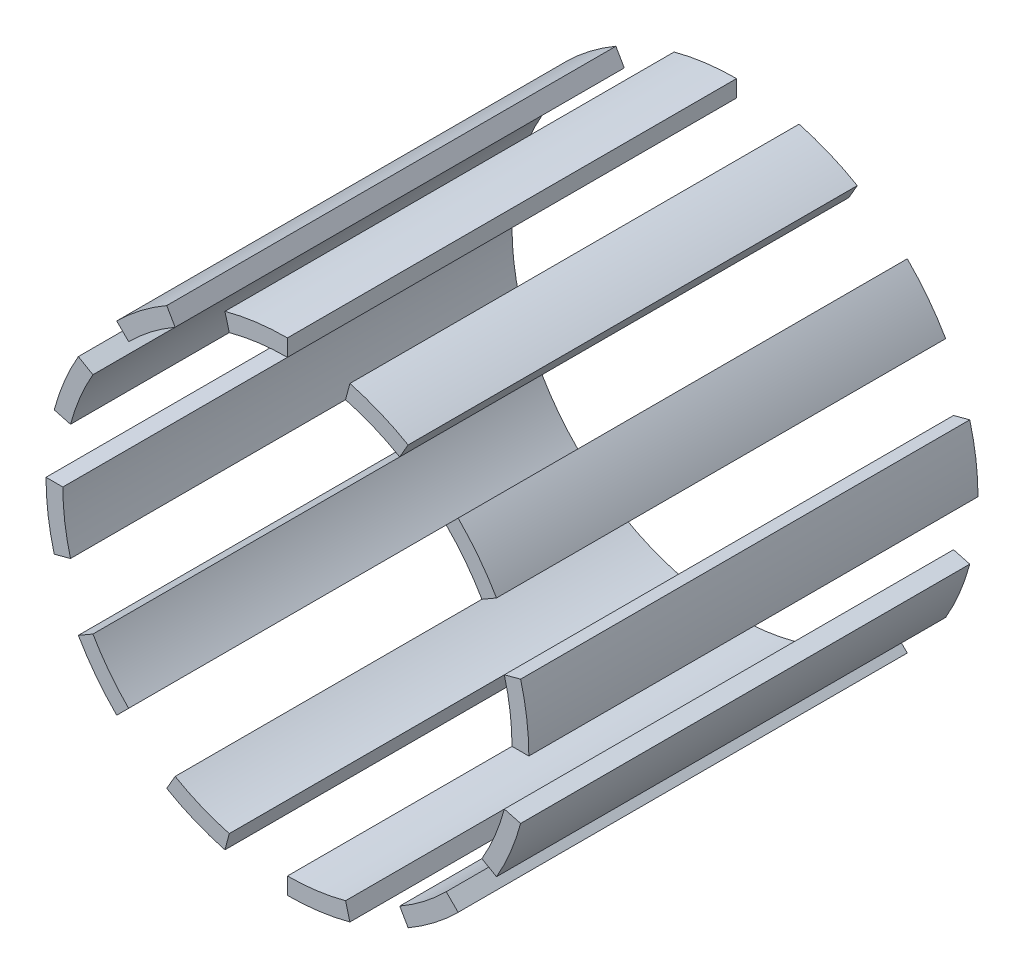
from build123d import *

# Parameters (mm, degrees)
BOSS_EXTRU_1_DEPTH    = 16
BOSS_EXTRU_1_2_DEPTH  = 16
BOSS_EXTRU_1_3_DEPTH  = 16
BOSS_EXTRU_1_4_DEPTH  = 16
BOSS_EXTRU_1_5_DEPTH  = 16
BOSS_EXTRU_1_6_DEPTH  = 16
BOSS_EXTRU_1_7_DEPTH  = 16
BOSS_EXTRU_1_8_DEPTH  = 16
BOSS_EXTRU_1_9_DEPTH  = 16
BOSS_EXTRU_1_10_DEPTH = 16
BOSS_EXTRU_1_11_DEPTH = 16
BOSS_EXTRU_1_12_DEPTH = 16


with BuildPart() as part:
    # Esquisse1 → Boss.-Extru.1 (new body)
    with BuildSketch(Plane.XY):
        with BuildLine():
            Line((8, 0), (8.6, 0))
            ThreePointArc((8.6, 0), (8.526425808, 1.122525253), (8.306962106, 2.225843788))
            Line((8.306962106, 2.225843788), (7.72740661, 2.070552361))
            ThreePointArc((7.72740661, 2.070552361), (7.931558891, 1.044209538), (8, 0))
        make_face()
    extrude(amount=BOSS_EXTRU_1_DEPTH)


with BuildPart() as body_2:
    # Esquisse1 → Boss.-Extru.1 2 (new body)
    with BuildSketch(Plane.XY):
        with BuildLine():
            Line((7.72740661, -2.070552361), (8.306962106, -2.225843788))
            ThreePointArc((8.306962106, -2.225843788), (7.94536398, -3.291077518), (7.447818473, -4.3))
            Line((7.447818473, -4.3), (6.92820323, -4))
            ThreePointArc((6.92820323, -4), (7.39103626, -3.061467459), (7.72740661, -2.070552361))
        make_face()
    extrude(amount=BOSS_EXTRU_1_2_DEPTH)


with BuildPart() as body_3:
    # Esquisse1 → Boss.-Extru.1 3 (new body)
    with BuildSketch(Plane.XY):
        with BuildLine():
            Line((5.656854249, -5.656854249), (6.081118318, -6.081118318))
            ThreePointArc((6.081118318, -6.081118318), (5.235348289, -6.822838727), (4.3, -7.447818473))
            Line((4.3, -7.447818473), (4, -6.92820323))
            ThreePointArc((4, -6.92820323), (4.870091432, -6.346826722), (5.656854249, -5.656854249))
        make_face()
    extrude(amount=BOSS_EXTRU_1_3_DEPTH)


with BuildPart() as body_4:
    # Esquisse1 → Boss.-Extru.1 4 (new body)
    with BuildSketch(Plane.XY):
        with BuildLine():
            Line((2.070552361, -7.72740661), (2.225843788, -8.306962106))
            ThreePointArc((2.225843788, -8.306962106), (1.122525253, -8.526425808), (0, -8.6))
            Line((0, -8.6), (0, -8))
            ThreePointArc((0, -8), (1.044209538, -7.931558891), (2.070552361, -7.72740661))
        make_face()
    extrude(amount=BOSS_EXTRU_1_4_DEPTH)


with BuildPart() as body_5:
    # Esquisse1 → Boss.-Extru.1 5 (new body)
    with BuildSketch(Plane.XY):
        with BuildLine():
            Line((-2.070552361, -7.72740661), (-2.225843788, -8.306962106))
            ThreePointArc((-2.225843788, -8.306962106), (-3.291077518, -7.94536398), (-4.3, -7.447818473))
            Line((-4.3, -7.447818473), (-4, -6.92820323))
            ThreePointArc((-4, -6.92820323), (-3.061467459, -7.39103626), (-2.070552361, -7.72740661))
        make_face()
    extrude(amount=BOSS_EXTRU_1_5_DEPTH)


with BuildPart() as body_6:
    # Esquisse1 → Boss.-Extru.1 6 (new body)
    with BuildSketch(Plane.XY):
        with BuildLine():
            Line((-5.656854249, -5.656854249), (-6.081118318, -6.081118318))
            ThreePointArc((-6.081118318, -6.081118318), (-6.822838727, -5.235348289), (-7.447818473, -4.3))
            Line((-7.447818473, -4.3), (-6.92820323, -4))
            ThreePointArc((-6.92820323, -4), (-6.346826722, -4.870091432), (-5.656854249, -5.656854249))
        make_face()
    extrude(amount=BOSS_EXTRU_1_6_DEPTH)


with BuildPart() as body_7:
    # Esquisse1 → Boss.-Extru.1 7 (new body)
    with BuildSketch(Plane.XY):
        with BuildLine():
            Line((-7.72740661, -2.070552361), (-8.306962106, -2.225843788))
            ThreePointArc((-8.306962106, -2.225843788), (-8.526425808, -1.122525253), (-8.6, 0))
            Line((-8.6, 0), (-8, 0))
            ThreePointArc((-8, 0), (-7.931558891, -1.044209538), (-7.72740661, -2.070552361))
        make_face()
    extrude(amount=BOSS_EXTRU_1_7_DEPTH)


with BuildPart() as body_8:
    # Esquisse1 → Boss.-Extru.1 8 (new body)
    with BuildSketch(Plane.XY):
        with BuildLine():
            Line((-7.72740661, 2.070552361), (-8.306962106, 2.225843788))
            ThreePointArc((-8.306962106, 2.225843788), (-7.94536398, 3.291077518), (-7.447818473, 4.3))
            Line((-7.447818473, 4.3), (-6.92820323, 4))
            ThreePointArc((-6.92820323, 4), (-7.39103626, 3.061467459), (-7.72740661, 2.070552361))
        make_face()
    extrude(amount=BOSS_EXTRU_1_8_DEPTH)


with BuildPart() as body_9:
    # Esquisse1 → Boss.-Extru.1 9 (new body)
    with BuildSketch(Plane.XY):
        with BuildLine():
            Line((-5.656854249, 5.656854249), (-6.081118318, 6.081118318))
            ThreePointArc((-6.081118318, 6.081118318), (-5.235348289, 6.822838727), (-4.3, 7.447818473))
            Line((-4.3, 7.447818473), (-4, 6.92820323))
            ThreePointArc((-4, 6.92820323), (-4.870091432, 6.346826722), (-5.656854249, 5.656854249))
        make_face()
    extrude(amount=BOSS_EXTRU_1_9_DEPTH)


with BuildPart() as body_10:
    # Esquisse1 → Boss.-Extru.1 10 (new body)
    with BuildSketch(Plane.XY):
        with BuildLine():
            Line((-2.070552361, 7.72740661), (-2.225843788, 8.306962106))
            ThreePointArc((-2.225843788, 8.306962106), (-1.122525253, 8.526425808), (0, 8.6))
            Line((0, 8.6), (0, 8))
            ThreePointArc((0, 8), (-1.044209538, 7.931558891), (-2.070552361, 7.72740661))
        make_face()
    extrude(amount=BOSS_EXTRU_1_10_DEPTH)


with BuildPart() as body_11:
    # Esquisse1 → Boss.-Extru.1 11 (new body)
    with BuildSketch(Plane.XY):
        with BuildLine():
            Line((2.070552361, 7.72740661), (2.225843788, 8.306962106))
            ThreePointArc((2.225843788, 8.306962106), (3.291077518, 7.94536398), (4.3, 7.447818473))
            Line((4.3, 7.447818473), (4, 6.92820323))
            ThreePointArc((4, 6.92820323), (3.061467459, 7.39103626), (2.070552361, 7.72740661))
        make_face()
    extrude(amount=BOSS_EXTRU_1_11_DEPTH)


with BuildPart() as body_12:
    # Esquisse1 → Boss.-Extru.1 12 (new body)
    with BuildSketch(Plane.XY):
        with BuildLine():
            Line((5.656854249, 5.656854249), (6.081118318, 6.081118318))
            ThreePointArc((6.081118318, 6.081118318), (6.822838727, 5.235348289), (7.447818473, 4.3))
            Line((7.447818473, 4.3), (6.92820323, 4))
            ThreePointArc((6.92820323, 4), (6.346826722, 4.870091432), (5.656854249, 5.656854249))
        make_face()
    extrude(amount=BOSS_EXTRU_1_12_DEPTH)


solid = Compound([part.part, body_2.part, body_3.part, body_4.part, body_5.part, body_6.part, body_7.part, body_8.part, body_9.part, body_10.part, body_11.part, body_12.part])
